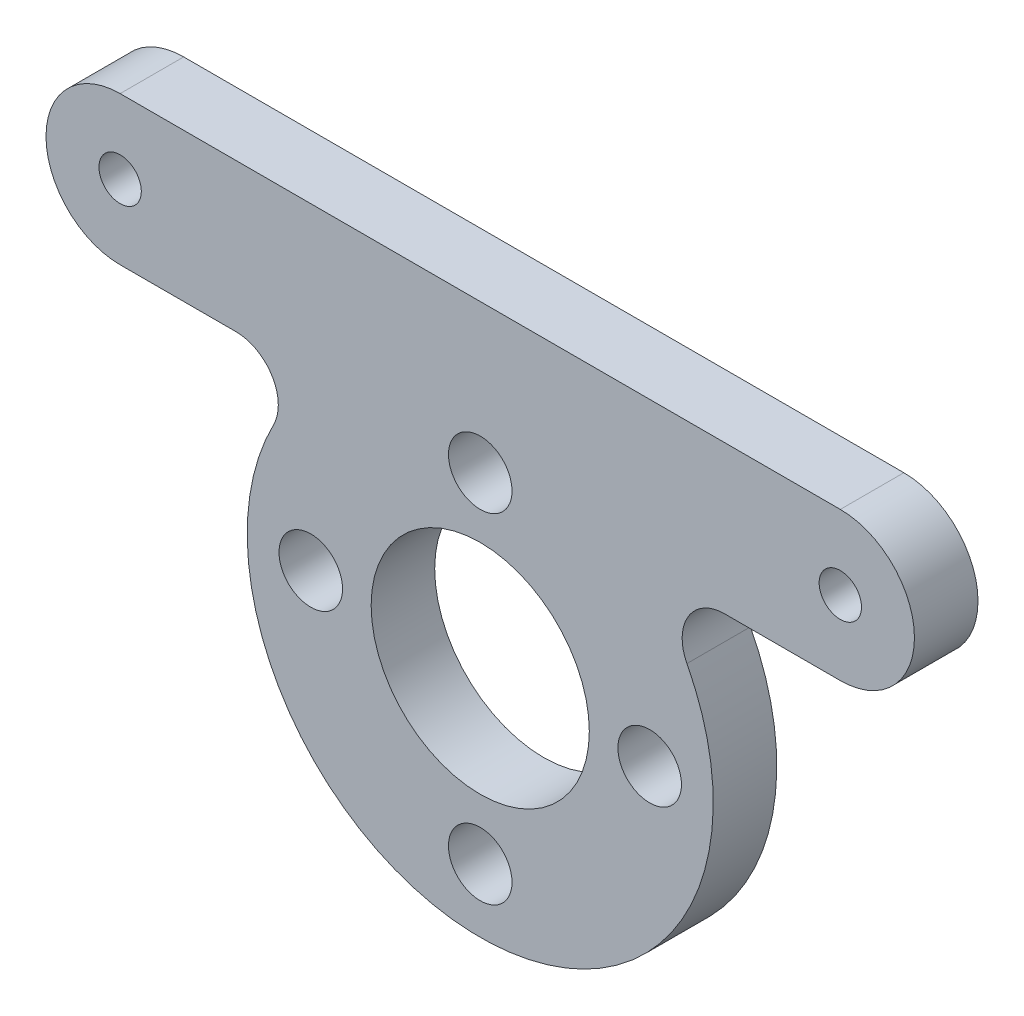
from build123d import *

# Parameters (mm, degrees)
EXTRUDE_1_DEPTH     = 3
SKETCH_2_R          = 5.15
SKETCH_2_R_2        = 1.5
SKETCH_2_R_3        = 1
CUT_EXTRUDE_1_DEPTH = 3
FILLET_1_R          = 2


with BuildPart() as part:
    # 草图1 → 凸台-拉伸1 (new body)
    with BuildSketch(Plane.XY):
        with BuildLine():
            Line((-17, 8), (-7.549834435, 8))
            ThreePointArc((-7.549834435, 8), (0, -11), (7.549834435, 8))
            Line((7.549834435, 8), (17, 8))
            ThreePointArc((17, 8), (20.5, 11.5), (17, 15))
            Line((17, 15), (-17, 15))
            ThreePointArc((-17, 15), (-20.5, 11.5), (-17, 8))
        make_face()
    extrude(amount=EXTRUDE_1_DEPTH)

    # 草图2 → 切除-拉伸1 (cut)
    with BuildSketch(Plane.XY.offset(3)):
        Circle(SKETCH_2_R)
        with Locations((8, 0)):
            Circle(SKETCH_2_R_2)
        with Locations((0, -8)):
            Circle(SKETCH_2_R_2)
        with Locations((-8, 0)):
            Circle(SKETCH_2_R_2)
        with Locations((0, 8)):
            Circle(SKETCH_2_R_2)
        with Locations((-17, 11.5)):
            Circle(SKETCH_2_R_3)
        with Locations((17, 11.5)):
            Circle(SKETCH_2_R_3)
    extrude(amount=-CUT_EXTRUDE_1_DEPTH, mode=Mode.SUBTRACT)

    # 圆角1
    fillet_1_edges = [part.edges().sort_by_distance(p)[0] for p in [
        (-7.549834435, 8, 1.5),
        (7.549834435, 8, 1.5),
    ]]
    fillet(fillet_1_edges, radius=FILLET_1_R)


solid = part.part
